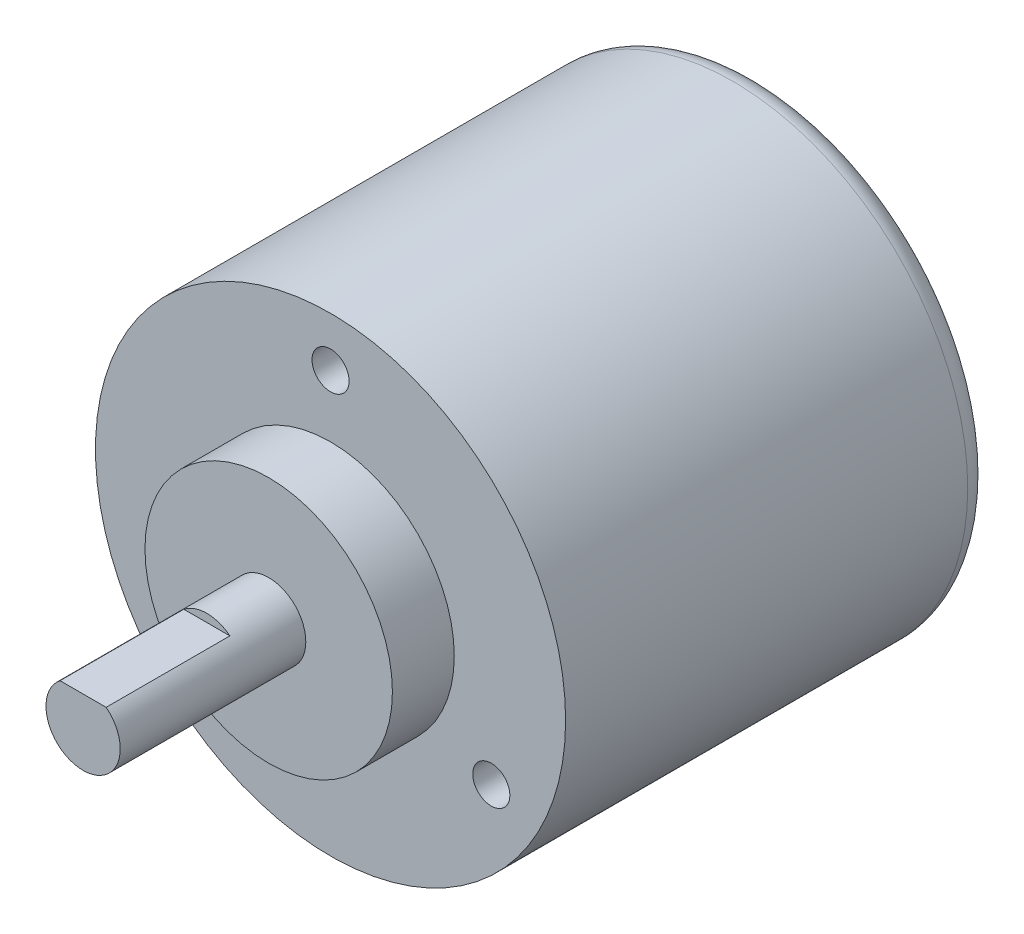
from build123d import *

# Parameters (mm, degrees)
SKETCH1_R               = 19
BOSS_EXTRUDE1_DEPTH     = 34.5
SKETCH2_R               = 10
BOSS_EXTRUDE2_DEPTH     = 5
SKETCH3_R               = 3
BOSS_EXTRUDE3_DEPTH     = 15
SKETCH4_W               = 10
SKETCH4_H               = 0.65
CUT_EXTRUDE1_DEPTH      = 20
CUT_EXTRUDE1_DEPTH_BACK = 20
FILLET1_R               = 2
SKETCH5_R               = 1.5
CUT_EXTRUDE2_DEPTH      = 3


with BuildPart() as part:
    # Sketch1 → Boss-Extrude1 (new body)
    with BuildSketch(Plane.XY):
        Circle(SKETCH1_R)
    extrude(amount=BOSS_EXTRUDE1_DEPTH)

    # Sketch2 → Boss-Extrude2 (add)
    with BuildSketch(Plane.XY.offset(34.5)):
        Circle(SKETCH2_R)
    extrude(amount=BOSS_EXTRUDE2_DEPTH)

    # Sketch3 → Boss-Extrude3 (add)
    with BuildSketch(Plane.XY.offset(39.5)):
        Circle(SKETCH3_R)
    extrude(amount=BOSS_EXTRUDE3_DEPTH)

    # Sketch4 → Cut-Extrude1 (cut, two sides)
    with BuildSketch(Plane(origin=(0, 0, 0), x_dir=(0, 0, -1), z_dir=(1, 0, 0))) as cut_extrude1_sk:
        with Locations((-49.5, 2.675)):
            Rectangle(SKETCH4_W, SKETCH4_H)
    extrude(amount=CUT_EXTRUDE1_DEPTH, mode=Mode.SUBTRACT)
    extrude(cut_extrude1_sk.sketch, amount=-CUT_EXTRUDE1_DEPTH_BACK, mode=Mode.SUBTRACT)

    # Fillet1
    fillet1_edges = [part.edges().sort_by_distance(p)[0] for p in [
        (-19, 0, 0),
    ]]
    fillet(fillet1_edges, radius=FILLET1_R)

    # Sketch5 → Cut-Extrude2 (cut)
    with BuildSketch(Plane.XY.offset(34.5)):
        with Locations((0, 15)):
            Circle(SKETCH5_R)
        with Locations((12.990381057, -7.5)):
            Circle(SKETCH5_R)
        with Locations((-12.990381057, -7.5)):
            Circle(SKETCH5_R)
    extrude(amount=-CUT_EXTRUDE2_DEPTH, mode=Mode.SUBTRACT)


solid = part.part
